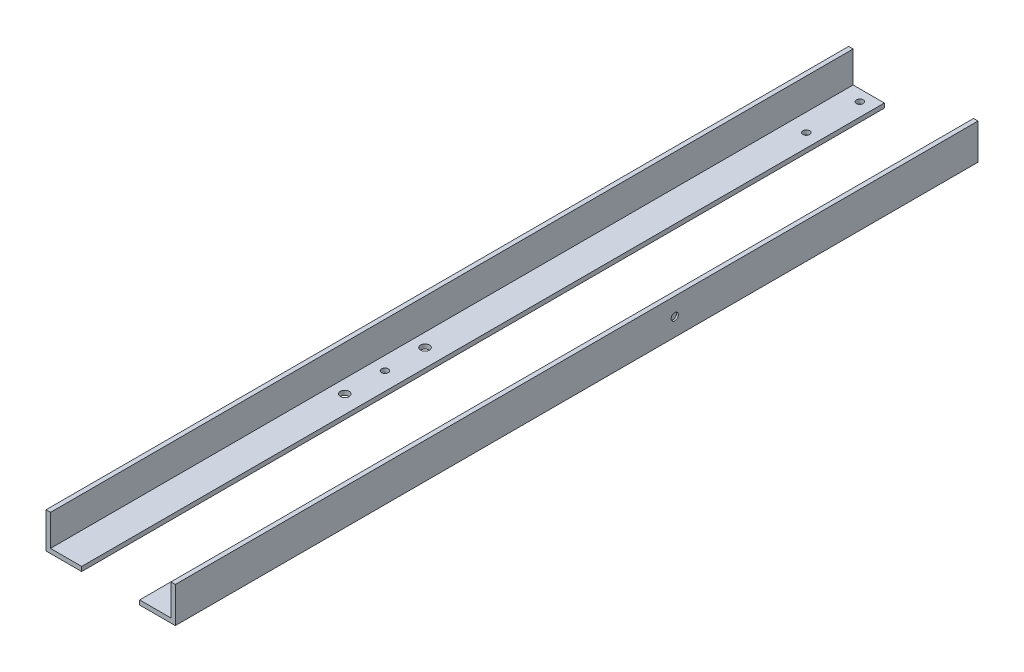
from build123d import *

# Parameters (mm, degrees)
SKETCH1_W            = 184.15
SKETCH1_H            = 1143
BOSS_EXTRUDE1_DEPTH  = 50.8
CUT_EXTRUDE1_DEPTH   = 1144
SKETCH3_R            = 4.7625
SKETCH3_R_2          = 6.35
BOLT_HOLE_CUTS_DEPTH = 7.35
SKETCH4_R            = 5.1308
CUT_EXTRUDE2_DEPTH   = 2.54


with BuildPart() as part:
    # Sketch1 → Boss-Extrude1 (new body)
    with BuildSketch(Plane(origin=(0, 0, 0), x_dir=(1, 0, 0), z_dir=(0, 1, 0))):
        Rectangle(SKETCH1_W, SKETCH1_H)
    extrude(amount=BOSS_EXTRUDE1_DEPTH)

    # Sketch2 → Cut-Extrude1 (cut, through all)
    with BuildSketch(Plane.XY.offset(571.5)):
        Polygon((-85.725, 50.8), (85.725, 50.8), (85.725, 6.35), (41.275, 6.35), (41.275, 0), (-41.275, 0), (-41.275, 6.35), (-85.725, 6.35), align=None)
    extrude(amount=-CUT_EXTRUDE1_DEPTH, mode=Mode.SUBTRACT)

    # Sketch3 → Bolt Hole Cuts (cut, through all)
    with BuildSketch(Plane(origin=(0, 6.35, 0), x_dir=(1, 0, 0), z_dir=(0, 1, 0))):
        with Locations((-60.325, 555.625)):
            Circle(SKETCH3_R)
        with Locations((-60.325, 479.425)):
            Circle(SKETCH3_R)
        with Locations((-66.675, -114.3)):
            Circle(SKETCH3_R)
        with Locations((60.325, 555.625)):
            Circle(SKETCH3_R)
        with Locations((60.325, 479.425)):
            Circle(SKETCH3_R)
        with Locations((60.325, -114.3)):
            Circle(SKETCH3_R)
        with Locations((-66.675, -57.15)):
            Circle(SKETCH3_R_2)
        with Locations((-66.675, -171.45)):
            Circle(SKETCH3_R_2)
        with Locations((60.325, -57.15)):
            Circle(SKETCH3_R_2)
        with Locations((60.325, -171.45)):
            Circle(SKETCH3_R_2)
    extrude(amount=-BOLT_HOLE_CUTS_DEPTH, mode=Mode.SUBTRACT)

    # Sketch4 → Cut-Extrude2 (cut)
    with BuildSketch(Plane(origin=(92.075, 0, 0), x_dir=(0, 0, -1), z_dir=(1, 0, 0))):
        with Locations((139.7, 25.4)):
            Circle(SKETCH4_R)
    extrude(amount=-CUT_EXTRUDE2_DEPTH, mode=Mode.SUBTRACT)


solid = part.part
